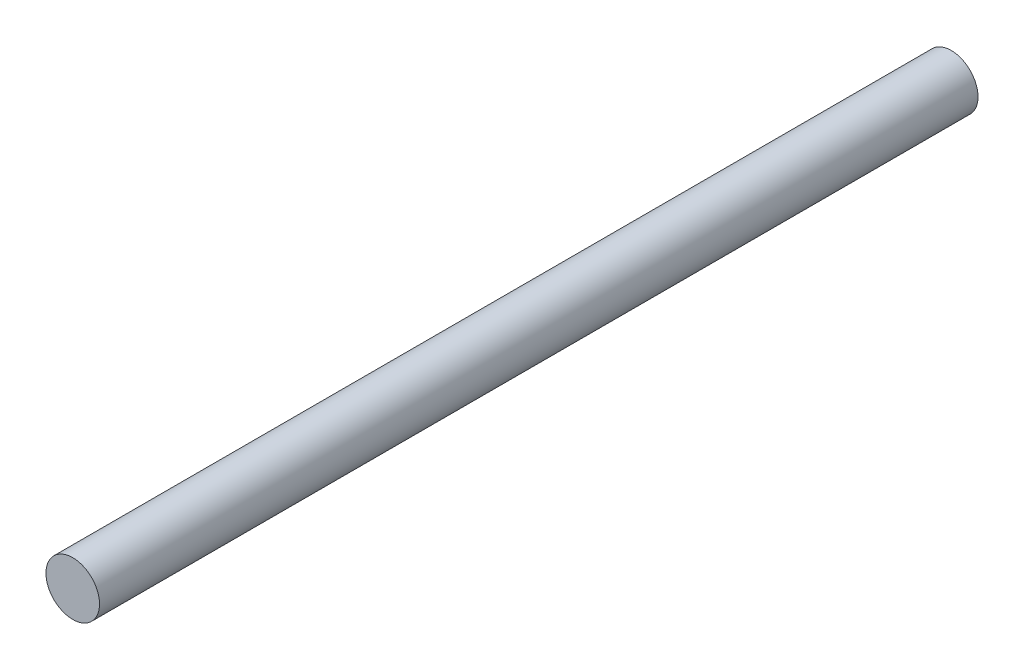
from build123d import *

# Parameters (mm, degrees)
SKETCH1_R      = 3.96875
EXTRUDE1_DEPTH = 65.0875


with BuildPart() as part:
    # Sketch1 → Extrude1 (new body, symmetric)
    with BuildSketch(Plane.XY):
        Circle(SKETCH1_R)
    extrude(amount=EXTRUDE1_DEPTH, both=True)


solid = part.part
